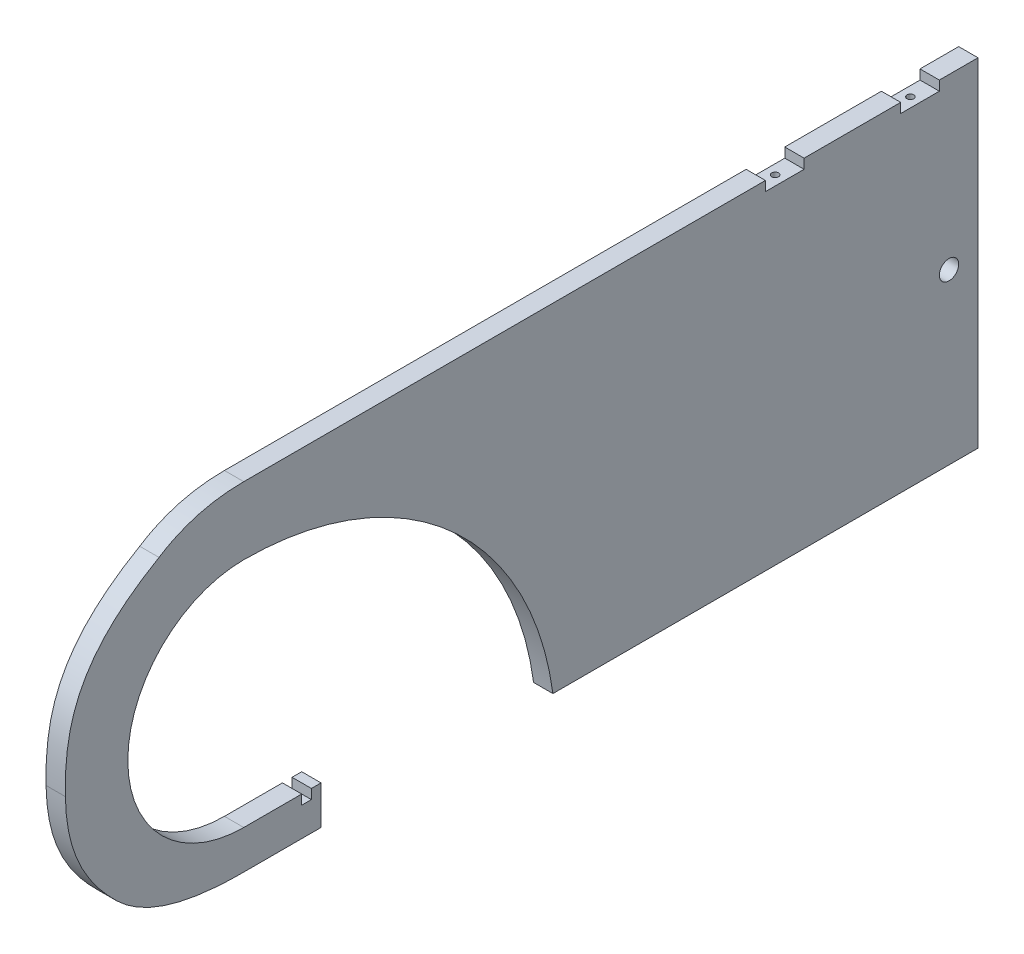
from build123d import *

# Parameters (mm, degrees)
SKETCH1_R                 = 3.175
BOSS_EXTRUDE2_DEPTH       = 3.175
F_4_40_TAPPED_HOLE1_D     = 2.2606
F_4_40_TAPPED_HOLE1_DEPTH = 7.62
F_4_40_TAPPED_HOLE1_TIP   = 0.679152758


with BuildPart() as part:
    # Sketch1 → Boss-Extrude2 (new body, symmetric)
    with BuildSketch(Plane(origin=(0, 0, 0), x_dir=(0, 0, -1), z_dir=(1, 0, 0))):
        with BuildLine():
            Line((25.4, -50.8), (25.4, -38.1))
            Line((25.4, -38.1), (22.225, -38.1))
            Line((22.225, -38.1), (22.225, -41.275))
            Line((22.225, -41.275), (19.05, -41.275))
            Line((19.05, -41.275), (19.05, -38.1))
            Line((19.05, -38.1), (0, -38.1))
            ThreePointArc((0, -38.1), (-38.1, 0), (0, 38.1))
            ThreePointArc((0, 38.1), (67.501425911, 12.737343898), (101.6, -50.8))
            Line((101.6, -50.8), (241.3, -50.8))
            Line((241.3, -50.8), (241.3, 60.325))
            Line((241.3, 60.325), (228.6, 60.325))
            Line((228.6, 60.325), (228.6, 57.15))
            Line((228.6, 57.15), (215.9, 57.15))
            Line((215.9, 57.15), (215.9, 60.325))
            Line((215.9, 60.325), (184.15, 60.325))
            Line((184.15, 60.325), (184.15, 57.15))
            Line((184.15, 57.15), (171.45, 57.15))
            Line((171.45, 57.15), (171.45, 60.325))
            Line((171.45, 60.325), (0, 60.325))
            add(Edge.make_bspline(
                [(-27.840906439, 52.6855483), (-15.97034645, 60.327815279), (0, 60.325)],
                knots=[0.821555454, 0.821555454, 0.821555454, 1, 1, 1], degree=2))
            add(Edge.make_bspline(
                [(-58.625125689, 0), (-58.995342849, 19.785116254), (-54.931758321, 37.043947765), (-27.840906439, 52.6855483)],
                knots=[0.494452285, 0.494452285, 0.494452285, 0.494452285, 0.821555454, 0.821555454, 0.821555454, 0.821555454], degree=3))
            add(Edge.make_bspline(
                [(-41.752199567, -38.1), (-52.707301474, -27.360886787), (-58.323372846, -16.126251656), (-58.625125689, 0)],
                knots=[0.219145, 0.219145, 0.219145, 0.219145, 0.494452285, 0.494452285, 0.494452285, 0.494452285], degree=3))
            add(Edge.make_bspline(
                [(0, -50.8), (-28.671783901, -50.922524692), (-41.752199567, -38.1)],
                knots=[0, 0, 0, 0.219145, 0.219145, 0.219145], degree=2))
            Line((0, -50.8), (25.4, -50.8))
        make_face()
        with Locations((231.775, 4.7625)):
            Circle(SKETCH1_R, mode=Mode.SUBTRACT)
    extrude(amount=BOSS_EXTRUDE2_DEPTH, both=True)

    # #4-40 Tapped Hole1
    with Locations(Plane(origin=(0, 57.15, 0), x_dir=(1, 0, 0), z_dir=(0, 1, 0))):
        with Locations((0, 177.8), (0, 222.25)):
            Hole(F_4_40_TAPPED_HOLE1_D / 2, depth=F_4_40_TAPPED_HOLE1_DEPTH)
            with Locations((0, 0, -(F_4_40_TAPPED_HOLE1_DEPTH + F_4_40_TAPPED_HOLE1_TIP / 2))):  # 118° drill point
                Cone(0, F_4_40_TAPPED_HOLE1_D / 2, F_4_40_TAPPED_HOLE1_TIP, mode=Mode.SUBTRACT)


solid = part.part
